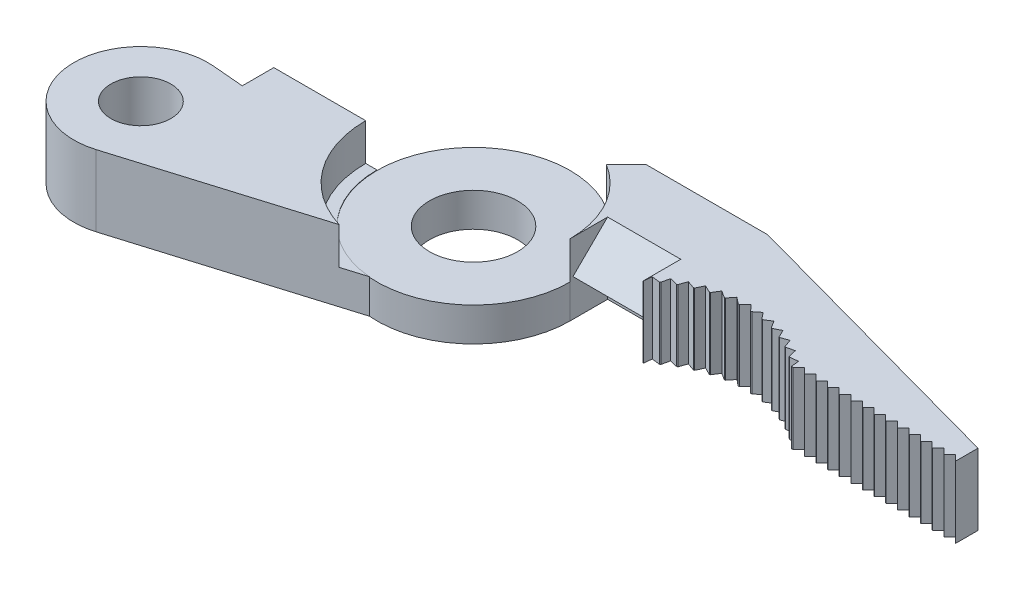
from build123d import *

# Parameters (mm, degrees)
SKETCH1_R                        = 6.5405
SKETCH1_R_2                      = 2.9845
BOSS_EXTRUDE1_DEPTH              = 4.826
SKETCH2_R                        = 2.032
BOSS_EXTRUDE2_DEPTH              = 4.826
F_42_0_0935_DIAMETER_HOLE1_D     = 2.3749
F_42_0_0935_DIAMETER_HOLE1_DEPTH = 2.032
F_42_0_0935_DIAMETER_HOLE1_TIP   = 0.713491942
BOSS_EXTRUDE3_DEPTH              = 4.826
CUT_EXTRUDE1_DEPTH               = 2.50825
CUT_EXTRUDE2_DEPTH               = 5.826
LPATTERN1_COUNT                  = 14
LPATTERN1_PITCH                  = 0.7874
CUT_EXTRUDE3_DEPTH               = 5.826
CIRPATTERN1_COUNT                = 13
CIRPATTERN1_ANGLE                = 76.5
SKETCH13_W                       = 4.953
SKETCH13_H                       = 2.54
CUT_EXTRUDE5_DEPTH               = 2.50825
BOSS_EXTRUDE4_REACH              = 28.099
SKETCH15_W                       = 4.953
SKETCH15_H                       = 2.54
CUT_EXTRUDE6_DEPTH               = 2.50825
SKETCH16_R                       = 6.5405
CUT_EXTRUDE7_DEPTH               = 2.54


with BuildPart() as part:
    # Sketch1 → Boss-Extrude1 (new body)
    with BuildSketch(Plane(origin=(0, 0, 0), x_dir=(1, 0, 0), z_dir=(0, 1, 0))):
        Circle(SKETCH1_R)
        Circle(SKETCH1_R_2, mode=Mode.SUBTRACT)
    extrude(amount=BOSS_EXTRUDE1_DEPTH)

    # Sketch2 → Boss-Extrude2 (add)
    with BuildSketch(Plane(origin=(0, 0, 0), x_dir=(1, 0, 0), z_dir=(0, 1, 0))):
        with BuildLine():
            Line((-6.5405, 0), (-13.5255, 0))
            Line((-13.5255, 0), (-13.5255, -2.137742196))
            Line((-13.5255, -2.137742196), (-15.655107442, -1.951425687))
            ThreePointArc((-15.655107442, -1.951425687), (-20.569516848, -6.947096437), (-14.732, -10.824149842))
            Line((-14.732, -10.824149842), (-0.540673648, -6.518114164))
            ThreePointArc((-0.540673648, -6.518114164), (-4.812193691, -4.429552136), (-6.5405, 0))
        make_face()
        with Locations((-16.05104389, -6.477)):
            Circle(SKETCH2_R, mode=Mode.SUBTRACT)
    extrude(amount=BOSS_EXTRUDE2_DEPTH)

    # #42 (0.0935) Diameter Hole1
    with Locations(Plane(origin=(0, 0, 0), x_dir=(-1, 0, 0), z_dir=(0, 0, -1))):
        with Locations((10.033, 2.413)):
            Hole(F_42_0_0935_DIAMETER_HOLE1_D / 2, depth=F_42_0_0935_DIAMETER_HOLE1_DEPTH)
            with Locations((0, 0, -(F_42_0_0935_DIAMETER_HOLE1_DEPTH + F_42_0_0935_DIAMETER_HOLE1_TIP / 2))):  # 118° drill point
                Cone(0, F_42_0_0935_DIAMETER_HOLE1_D / 2, F_42_0_0935_DIAMETER_HOLE1_TIP, mode=Mode.SUBTRACT)

    # Sketch8 → Boss-Extrude3 (add)
    with BuildSketch(Plane(origin=(0, 0, 0), x_dir=(1, 0, 0), z_dir=(0, 1, 0))):
        with BuildLine():
            Line((13.001568547, 6.9215), (32.639, 1.524))
            Line((32.639, 1.524), (32.639, 0))
            Line((32.639, 0), (21.5265, 0))
            ThreePointArc((21.5265, 0), (16.51, 1.884223876), (11.4935, 0))
            Line((11.4935, 0), (6.5405, 0))
            ThreePointArc((6.5405, 0), (5.703778696, 3.200788783), (3.407697053, 5.582628507))
            Line((3.407697053, 5.582628507), (4.746568547, 6.9215))
            Line((4.746568547, 6.9215), (13.001568547, 6.9215))
        make_face()
    extrude(amount=BOSS_EXTRUDE3_DEPTH)

    # Sketch9 → Cut-Extrude1 (cut)
    with BuildSketch(Plane(origin=(0, 4.826, 0), x_dir=(1, 0, 0), z_dir=(0, 1, 0))):
        with BuildLine():
            ThreePointArc((-7.3025, 0), (-5.860688184, -4.356471079), (-2.10459784, -6.992651442))
            Line((-2.10459784, -6.992651442), (-0.540673648, -6.518114164))
            ThreePointArc((-0.540673648, -6.518114164), (-4.812193691, -4.429552136), (-6.5405, 0))
            Line((-6.5405, 0), (-7.3025, 0))
        make_face()
    extrude(amount=-CUT_EXTRUDE1_DEPTH, mode=Mode.SUBTRACT)

    # Sketch10 → Cut-Extrude2 (cut, through all)
    with BuildSketch(Plane(origin=(0, 4.826, 0), x_dir=(1, 0, 0), z_dir=(0, 1, 0))):
        Polygon((32.639, 0), (32.258, 0.381), (31.877, 0), align=None)
    cut_extrude2 = extrude(amount=-CUT_EXTRUDE2_DEPTH, mode=Mode.SUBTRACT)

    # LPattern1: Cut-Extrude2 ×14
    with Locations(*[(-i * LPATTERN1_PITCH, 0, 0) for i in range(1, LPATTERN1_COUNT)]):
        add(cut_extrude2, mode=Mode.SUBTRACT)

    # Sketch11 → Cut-Extrude3 (cut, through all)
    with BuildSketch(Plane(origin=(0, 4.826, 0), x_dir=(1, 0, 0), z_dir=(0, 1, 0))):
        with BuildLine():
            Line((21.5265, 0), (21.464606941, 0.546569859))
            Line((21.464606941, 0.546569859), (20.918663717, 0.47937345))
            ThreePointArc((20.918663717, 0.47937345), (21.228673277, 0.247410527), (21.5265, 0))
        make_face()
    cut_extrude3 = extrude(amount=-CUT_EXTRUDE3_DEPTH, mode=Mode.SUBTRACT)

    # CirPattern1: Cut-Extrude3 ×13 about axis
    cirpattern1_axis = Axis((16.51, 0, 5.735776124), (0, 1, 0))
    for i in range(1, CIRPATTERN1_COUNT):
        add(cut_extrude3.rotate(cirpattern1_axis, i * CIRPATTERN1_ANGLE / (CIRPATTERN1_COUNT - 1)), mode=Mode.SUBTRACT)

    # Sketch13 → Cut-Extrude5 (cut)
    with BuildSketch(Plane(origin=(0, 4.826, 0), x_dir=(1, 0, 0), z_dir=(0, 1, 0))):
        with Locations((9.017, 1.27)):
            Rectangle(SKETCH13_W, SKETCH13_H)
    extrude(amount=-CUT_EXTRUDE5_DEPTH, mode=Mode.SUBTRACT)

    # Sketch14 → Boss-Extrude4 (add, up to next)
    with BuildSketch(Plane(origin=(6.5405, 0, 0), x_dir=(0, 0, -1), z_dir=(1, 0, 0)), mode=Mode.PRIVATE) as boss_extrude4_sk1:
        Polygon((0, 2.31775), (2.54, 4.826), (2.54, 2.31775), align=None)
    boss_extrude4_tool1 = extrude(boss_extrude4_sk1.sketch, amount=BOSS_EXTRUDE4_REACH, mode=Mode.PRIVATE) - part.part
    add(boss_extrude4_tool1.solids().sort_by_distance((6.5405, 3.153833, -1.693333))[0])

    # Sketch15 → Cut-Extrude6 (cut)
    with BuildSketch(Plane.XZ):
        with Locations((9.017, -1.27)):
            Rectangle(SKETCH15_W, SKETCH15_H)
    extrude(amount=-CUT_EXTRUDE6_DEPTH, mode=Mode.SUBTRACT)

    # Sketch16 → Cut-Extrude7 (cut)
    with BuildSketch(Plane(origin=(0, 4.826, 0), x_dir=(1, 0, 0), z_dir=(0, 1, 0))):
        Circle(SKETCH16_R)
    extrude(amount=-CUT_EXTRUDE7_DEPTH, mode=Mode.SUBTRACT)


solid = part.part
